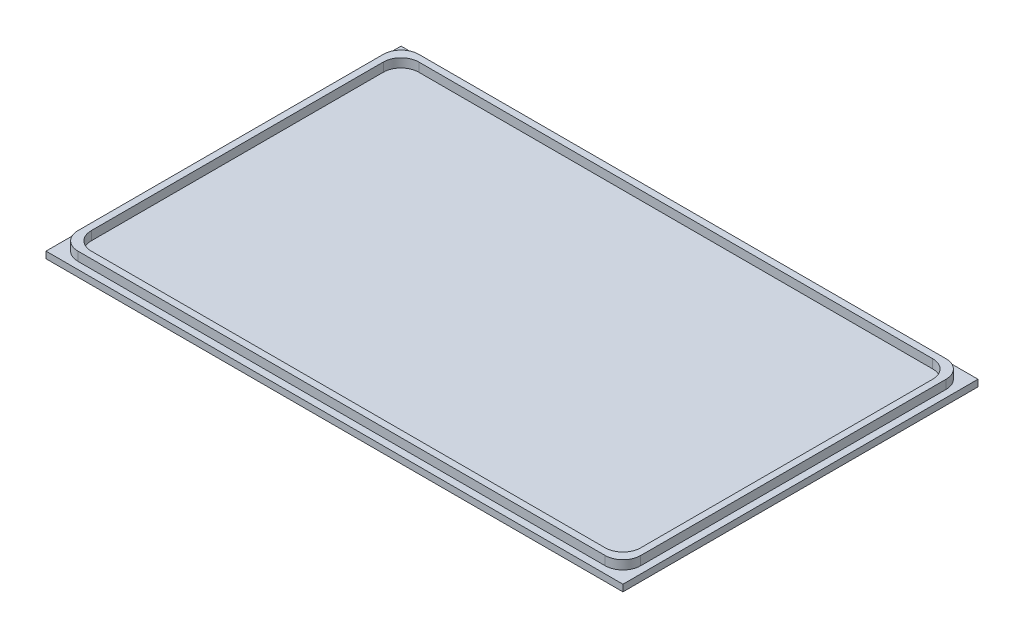
from build123d import *

# Parameters (mm, degrees)
SKETCH1_W           = 260
SKETCH1_H           = 160
BOSS_EXTRUDE1_DEPTH = 3
SKETCH2_W           = 253.6
SKETCH2_H           = 153.6
SKETCH2_W_2         = 247.6
SKETCH2_H_2         = 147.6
BOSS_EXTRUDE2_DEPTH = 4
FILLET1_R           = 8


with BuildPart() as part:
    # Sketch1 → Boss-Extrude1 (new body)
    with BuildSketch(Plane(origin=(0, 0, 0), x_dir=(1, 0, 0), z_dir=(0, 1, 0))):
        Rectangle(SKETCH1_W, SKETCH1_H)
    extrude(amount=BOSS_EXTRUDE1_DEPTH)

    # Sketch2 → Boss-Extrude2 (add)
    with BuildSketch(Plane(origin=(0, 3, 0), x_dir=(1, 0, 0), z_dir=(0, 1, 0))):
        Rectangle(SKETCH2_W, SKETCH2_H)
        Rectangle(SKETCH2_W_2, SKETCH2_H_2, mode=Mode.SUBTRACT)
    extrude(amount=BOSS_EXTRUDE2_DEPTH)

    # Fillet1
    fillet1_edges = [part.edges().sort_by_distance(p)[0] for p in [
        (-126.8, 5, 76.8),
        (126.8, 5, 76.8),
        (126.8, 5, -76.8),
        (-126.8, 5, -76.8),
        (123.8, 5, 73.8),
        (123.8, 5, -73.8),
        (-123.8, 5, -73.8),
        (-123.8, 5, 73.8),
    ]]
    fillet(fillet1_edges, radius=FILLET1_R)


solid = part.part
